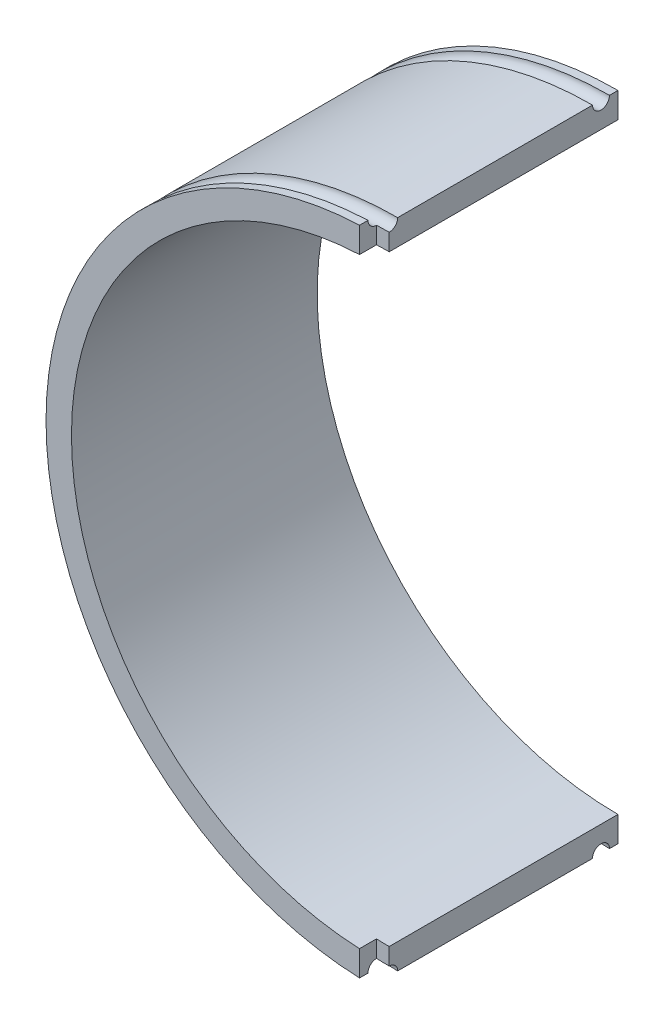
from build123d import *

# Parameters (mm, degrees)
MAIN_SHELL_DEPTH = 29
END_STOP_DEPTH   = 2


with BuildPart() as part:
    # Sketch1 → Main Shell (new body)
    with BuildSketch(Plane.XY):
        with BuildLine():
            Line((0, 38.5), (0, 35.5))
            ThreePointArc((0, 35.5), (-35.5, 0), (0, -35.5))
            Line((0, -35.5), (0, -38.5))
            ThreePointArc((0, -38.5), (-38.5, 0), (0, 38.5))
        make_face()
    extrude(amount=MAIN_SHELL_DEPTH)

    # Sketch3 → Rubber Band Holder (revolve, cut)
    with BuildSketch(Plane(origin=(0, 0, 0), x_dir=(0, 0, -1), z_dir=(1, 0, 0))):
        with BuildLine():
            Line((-28, 38.5), (-26, 38.5))
            ThreePointArc((-26, 38.5), (-27, 37.5), (-28, 38.5))
        make_face()
        with BuildLine():
            Line((-3, 38.5), (-1, 38.5))
            ThreePointArc((-1, 38.5), (-2, 37.5), (-3, 38.5))
        make_face()
    revolve(axis=Axis((0, 0, 29), (0, 0, -1)), mode=Mode.SUBTRACT)

    # Sketch4 → End Stop (cut)
    with BuildSketch(Plane.XY.offset(29)):
        with BuildLine():
            Line((0, 38.5), (0, 35.5))
            ThreePointArc((0, 35.5), (-0.750167508, 35.49207304), (-1.5, 35.468295702))
            Line((-1.5, 35.468295702), (-1.5, 38.470768123))
            ThreePointArc((-1.5, 38.470768123), (-0.750142404, 38.492691337), (0, 38.5))
        make_face()
        with BuildLine():
            Line((-1.5, -38.470768123), (-1.5, -35.468295702))
            ThreePointArc((-1.5, -35.468295702), (-0.750167508, -35.49207304), (0, -35.5))
            Line((0, -35.5), (0, -38.5))
            ThreePointArc((0, -38.5), (-0.750142404, -38.492691337), (-1.5, -38.470768123))
        make_face()
    extrude(amount=-END_STOP_DEPTH, mode=Mode.SUBTRACT)


solid = part.part
